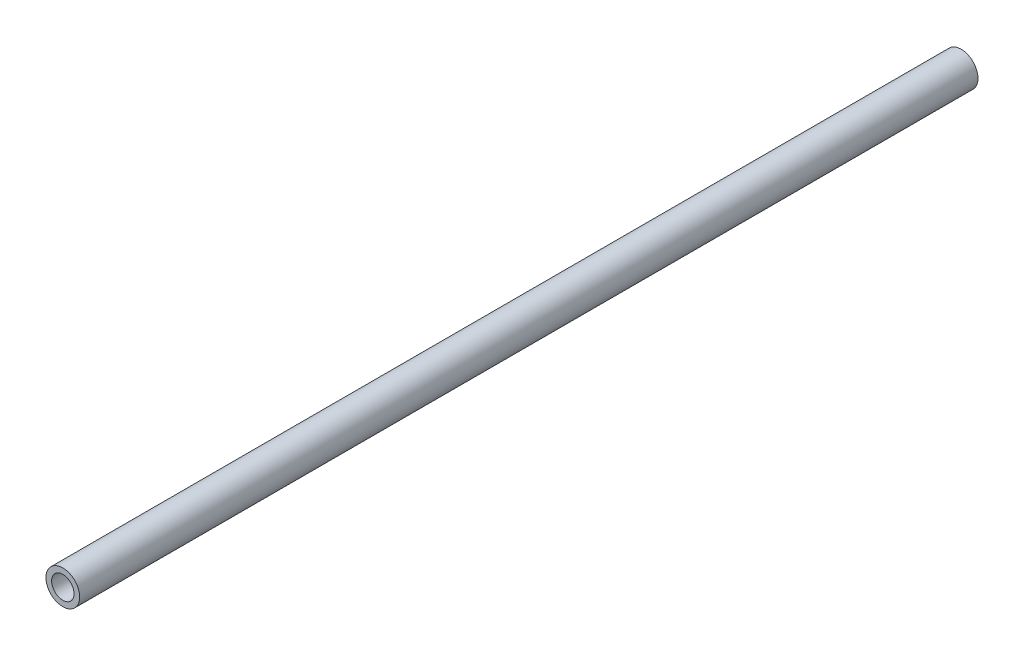
from build123d import *

# Parameters (mm, degrees)
SKETCH1_R           = 7.62
SKETCH1_R_2         = 5.08
BOSS_EXTRUDE1_DEPTH = 406.4


with BuildPart() as part:
    # Sketch1 → Boss-Extrude1 (new body)
    with BuildSketch(Plane.XY):
        Circle(SKETCH1_R)
        Circle(SKETCH1_R_2, mode=Mode.SUBTRACT)
    extrude(amount=BOSS_EXTRUDE1_DEPTH)


solid = part.part
